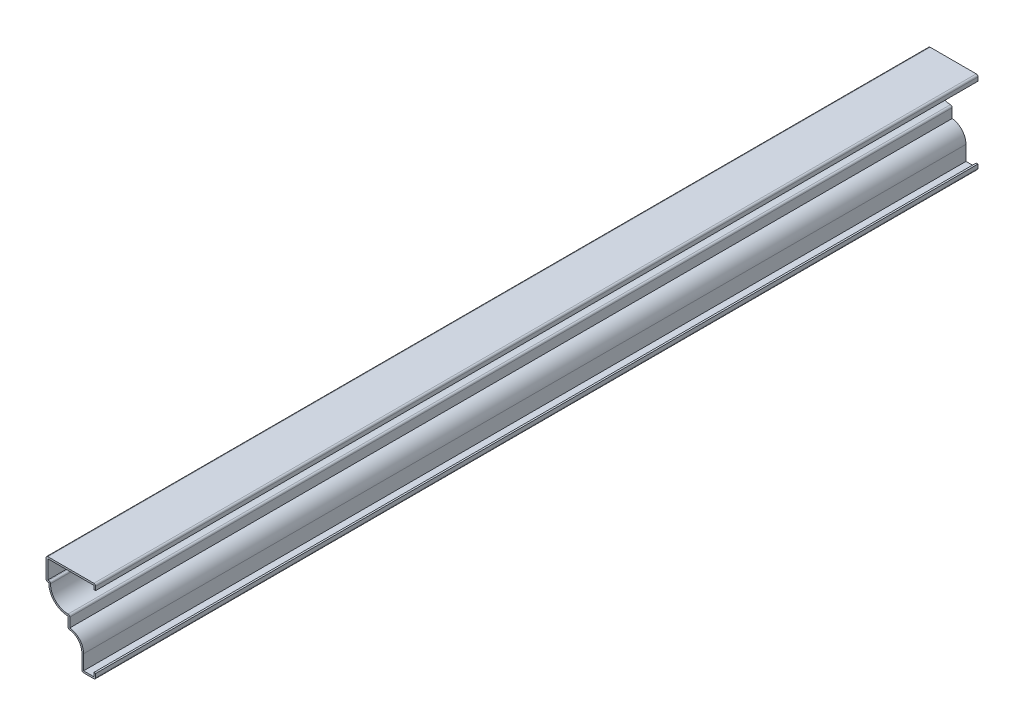
from build123d import *

# Parameters (mm, degrees)
EXTRUDE_THIN1_DEPTH = 508
FILLET1_R           = 1.016


with BuildPart() as part:
    # Sketch1 → Extrude-Thin1 (new body)
    with BuildSketch(Plane.XY):
        with BuildLine():
            Line((0, 3.175), (0, 0))
            Line((0, 0), (-7.9375, 0))
            Line((-7.9375, 0), (-7.9375, 9.525))
            ThreePointArc((-7.9375, 9.525), (-10.26234, 15.13766), (-15.875, 17.4625))
            Line((-15.875, 17.4625), (-15.875, 23.8125))
            ThreePointArc((-15.875, 23.8125), (-23.732724, 27.067276), (-26.9875, 34.925))
            Line((-26.9875, 34.925), (-28.575, 34.925))
            Line((-28.575, 34.925), (-28.575, 47.625))
            Line((-28.575, 47.625), (0, 47.625))
            Line((0, 47.625), (0, 44.45))
            Line((0, 44.45), (-1.016, 44.45))
            Line((-1.016, 44.45), (-1.016, 46.609))
            Line((-1.016, 46.609), (-27.559, 46.609))
            Line((-27.559, 46.609), (-27.559, 35.941))
            Line((-27.559, 35.941), (-25.92025, 35.941))
            ThreePointArc((-25.92025, 35.941), (-23.014304, 27.785696), (-14.859, 24.87975))
            Line((-14.859, 24.87975), (-14.859, 18.420668))
            ThreePointArc((-14.859, 18.420668), (-9.194359, 15.486057), (-6.9215, 9.525))
            Line((-6.9215, 9.525), (-6.9215, 1.016))
            Line((-6.9215, 1.016), (-1.016, 1.016))
            Line((-1.016, 1.016), (-1.016, 3.175))
            Line((-1.016, 3.175), (0, 3.175))
        make_face()
    extrude(amount=-EXTRUDE_THIN1_DEPTH)

    # Fillet1
    fillet1_edges = [part.edges().sort_by_distance(p)[0] for p in [
        (-25.92025, 35.941, -254),
        (-14.859, 24.87975, -254),
        (0, 0, -254),
        (-7.9375, 0, -254),
        (-15.875, 17.4625, -254),
        (-28.575, 34.925, -254),
        (-28.575, 47.625, -254),
        (0, 47.625, -254),
    ]]
    fillet(fillet1_edges, radius=FILLET1_R)


solid = part.part
